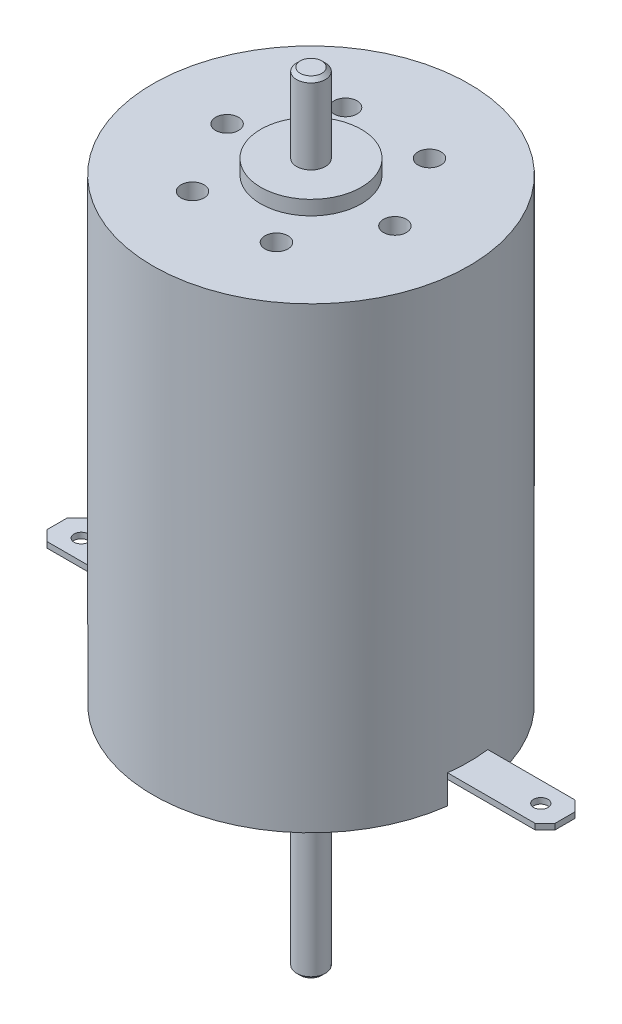
from build123d import *

# Parameters (mm, degrees)
ESQUISSE1_R                  = 11
EXTRUSION1_DEPTH             = 31.9
ESQUISSE2_R                  = 3.5
EXTRUSION2_DEPTH             = 1
ESQUISSE3_R                  = 1
EXTRUSION3_DEPTH             = 5.5
CHANFREIN1_SIZE              = 0.25
ESQUISSE4_R                  = 4
EXTRUSION4_DEPTH             = 2.5
ESQUISSE5_R                  = 1
EXTRUSION5_DEPTH             = 13.5
R_P_TITION_CIRCULAIRE1_COUNT = 6
CHANFREIN2_SIZE              = 0.25
ESQUISSE14_W                 = 3.416971917
ESQUISSE14_H                 = 2.8
ENL_V_MAT_EXTRU_5_DEPTH      = 2
R_P_TITION_CIRCULAIRE2_COUNT = 2
ESQUISSE16_W                 = 2.8
ESQUISSE16_H                 = 0.4
EXTRUSION7_DEPTH             = 9.2
ESQUISSE17_W                 = 2.8
ESQUISSE17_H                 = 0.4
EXTRUSION8_DEPTH             = 9.2
CHANFREIN3_SIZE              = 0.7
CHANFREIN4_SIZE              = 0.7
ESQUISSE18_R                 = 0.5
ENL_V_MAT_EXTRU_6_DEPTH      = 37.8
ESQUISSE19_R                 = 0.5
ENL_V_MAT_EXTRU_7_DEPTH      = 37.8


with BuildPart() as part:
    # Esquisse1 → Extrusion1 (new body)
    with BuildSketch(Plane(origin=(0, 0, 0), x_dir=(1, 0, 0), z_dir=(0, 1, 0))):
        Circle(ESQUISSE1_R)
    extrude(amount=EXTRUSION1_DEPTH)

    # Esquisse2 → Extrusion2 (add)
    with BuildSketch(Plane(origin=(0, 31.9, 0), x_dir=(1, 0, 0), z_dir=(0, 1, 0))):
        Circle(ESQUISSE2_R)
    extrude(amount=EXTRUSION2_DEPTH)

    # Esquisse3 → Extrusion3 (add)
    with BuildSketch(Plane(origin=(0, 32.9, 0), x_dir=(1, 0, 0), z_dir=(0, 1, 0))):
        Circle(ESQUISSE3_R)
    extrude(amount=EXTRUSION3_DEPTH)

    # Chanfrein1
    chanfrein1_edges = [part.edges().sort_by_distance(p)[0] for p in [
        (-1, 38.4, 0),
    ]]
    chamfer(chanfrein1_edges, length=CHANFREIN1_SIZE)

    # Esquisse4 → Extrusion4 (add)
    with BuildSketch(Plane.XZ):
        Circle(ESQUISSE4_R)
    extrude(amount=EXTRUSION4_DEPTH)

    # Esquisse5 → Extrusion5 (add)
    with BuildSketch(Plane.XZ.offset(2.5)):
        Circle(ESQUISSE5_R)
    extrude(amount=EXTRUSION5_DEPTH)

    # Esquisse7 → Trou taraudé M2x0.41 (revolve, cut)
    with BuildSketch(Plane(origin=(-2.865237062, 31.9, -5.271661653), x_dir=(0, 0, 1), z_dir=(1, 0, 0))):
        Polygon((0, 0), (0, 4.480688495), (0.8, 4), (0.8, 0), align=None)
    trou_taraud_m2x0_41 = revolve(axis=Axis((-2.865237062, 38.25, -5.271661653), (0, -1, 0)), mode=Mode.SUBTRACT)

    # Répétition circulaire1: Trou taraudé M2x0.41 ×6 about axis
    r_p_tition_circulaire1_axis = Axis((0, 0, 0), (0, 1, 0))
    for i in range(1, R_P_TITION_CIRCULAIRE1_COUNT):
        add(trou_taraud_m2x0_41.rotate(r_p_tition_circulaire1_axis, i * 360 / R_P_TITION_CIRCULAIRE1_COUNT), mode=Mode.SUBTRACT)

    # Chanfrein2
    chanfrein2_edges = [part.edges().sort_by_distance(p)[0] for p in [
        (-1, -16, 0),
    ]]
    chamfer(chanfrein2_edges, length=CHANFREIN2_SIZE)

    # Esquisse14 → Enlèv. mat.-Extru.5 (cut)
    with BuildSketch(Plane.XZ):
        with Locations((-10.208485959, 0)):
            Rectangle(ESQUISSE14_W, ESQUISSE14_H)
    enl_v_mat_extru_5 = extrude(amount=-ENL_V_MAT_EXTRU_5_DEPTH, mode=Mode.SUBTRACT)

    # Répétition circulaire2: Enlèv. mat.-Extru.5 ×2 about axis
    r_p_tition_circulaire2_axis = Axis((0, 0, 0), (0, 1, 0))
    for i in range(1, R_P_TITION_CIRCULAIRE2_COUNT):
        add(enl_v_mat_extru_5.rotate(r_p_tition_circulaire2_axis, i * 360 / R_P_TITION_CIRCULAIRE2_COUNT), mode=Mode.SUBTRACT)

    # Esquisse16 → Extrusion7 (add)
    with BuildSketch(Plane(origin=(8.5, 0, 0), x_dir=(0, 0, -1), z_dir=(1, 0, 0))):
        with Locations((0, 1.8)):
            Rectangle(ESQUISSE16_W, ESQUISSE16_H)
    extrude(amount=EXTRUSION7_DEPTH)

    # Esquisse17 → Extrusion8 (add)
    with BuildSketch(Plane.ZY.offset(8.5)):
        with Locations((0, 1.8)):
            Rectangle(ESQUISSE17_W, ESQUISSE17_H)
    extrude(amount=EXTRUSION8_DEPTH)

    # Chanfrein3
    chanfrein3_edges = [part.edges().sort_by_distance(p)[0] for p in [
        (17.7, 1.8, 1.4),
        (17.7, 1.8, -1.4),
    ]]
    chamfer(chanfrein3_edges, length=CHANFREIN3_SIZE)

    # Chanfrein4
    chanfrein4_edges = [part.edges().sort_by_distance(p)[0] for p in [
        (-17.7, 1.8, -1.4),
        (-17.7, 1.8, 1.4),
    ]]
    chamfer(chanfrein4_edges, length=CHANFREIN4_SIZE)

    # Esquisse18 → Enlèv. mat.-Extru.6 (cut, through all)
    with BuildSketch(Plane.XZ.offset(-1.6)):
        with Locations((-16, 0)):
            Circle(ESQUISSE18_R)
    extrude(amount=-ENL_V_MAT_EXTRU_6_DEPTH, mode=Mode.SUBTRACT)

    # Esquisse19 → Enlèv. mat.-Extru.7 (cut, through all)
    with BuildSketch(Plane.XZ.offset(-1.6)):
        with Locations((16, 0)):
            Circle(ESQUISSE19_R)
    extrude(amount=-ENL_V_MAT_EXTRU_7_DEPTH, mode=Mode.SUBTRACT)


solid = part.part
